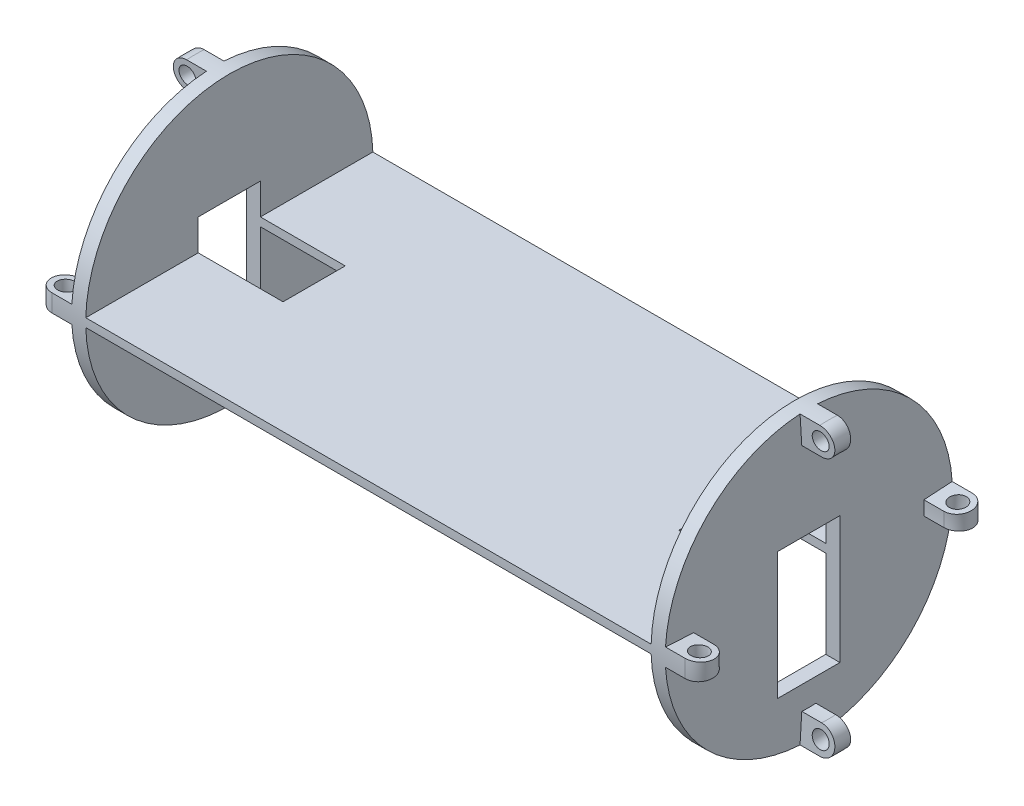
from build123d import *
from build123d.topology import SkipClean

# Parameters (mm, degrees)
SKETCH1_R               = 50.8
BOSS_EXTRUDE1_DEPTH     = 5
SKETCH2_W               = 22
SKETCH2_H               = 45
CUT_EXTRUDE1_DEPTH      = 5
SKETCH3_R               = 3
REVOLVE1_ANGLE          = 7
CIRPATTERN1_COUNT       = 4
SKETCH4_W               = 22
SKETCH4_H               = 3
BOSS_EXTRUDE2_DEPTH     = 200
SKETCH5_W               = 30
SKETCH5_H               = 22
CUT_EXTRUDE2_DEPTH      = 3
MIRROR1_COPY_1_SKETCH_R = 3
MIRROR1_COPY_1_ANGLE    = 7
MIRROR1_COPY_2_SKETCH_R = 3
MIRROR1_COPY_2_ANGLE    = 7
MIRROR1_COPY_3_SKETCH_R = 3
MIRROR1_COPY_3_ANGLE    = 7


with BuildPart() as part:
    # Sketch1 → Boss-Extrude1 (new body)
    with BuildSketch(Plane(origin=(0, 0, 0), x_dir=(0, 0, -1), z_dir=(1, 0, 0))):
        Circle(SKETCH1_R)
    boss_extrude1 = extrude(amount=-BOSS_EXTRUDE1_DEPTH)

    # Sketch2 → Cut-Extrude1 (cut)
    with BuildSketch(Plane(origin=(0, 0, 0), x_dir=(0, 0, -1), z_dir=(1, 0, 0))):
        with Locations((0, -10)):
            Rectangle(SKETCH2_W, SKETCH2_H)
    cut_extrude1 = extrude(amount=-CUT_EXTRUDE1_DEPTH, mode=Mode.SUBTRACT)

    # Sketch3 → Revolve1 (revolve, symmetric)
    with SkipClean():  # the faces are left unmerged after this step: merging them gives an invalid solid
        with BuildSketch(Plane.XY) as revolve1_sk:
            with BuildLine():
                Line((0, 50.8), (0, 40.8))
                Line((0, 40.8), (7, 40.8))
                ThreePointArc((7, 40.8), (12, 45.8), (7, 50.8))
                Line((7, 50.8), (0, 50.8))
            make_face()
            with Locations((7, 45.8)):
                Circle(SKETCH3_R, mode=Mode.SUBTRACT)
        revolve1 = revolve(axis=Axis((0, 0, 0), (1, 0, 0)), revolution_arc=REVOLVE1_ANGLE / 2)
        revolve1 = revolve1 + revolve(revolve1_sk.sketch, axis=Axis((0, 0, 0), (-1, 0, 0)), revolution_arc=REVOLVE1_ANGLE / 2)

    # CirPattern1: Revolve1 ×4 about axis
    cirpattern1_axis = Axis((-5, 0, 0), (1, 0, 0))
    for i in range(1, CIRPATTERN1_COUNT):
        add(revolve1.rotate(cirpattern1_axis, i * 360 / CIRPATTERN1_COUNT))

    # Sketch4 → Boss-Extrude2 (add)
    with BuildSketch(Plane.ZY.offset(5)):
        with BuildLine():
            ThreePointArc((50.8, 0), (50.794462074, 0.75008177), (50.777849502, 1.5))
            Line((50.777849502, 1.5), (11, 1.5))
            Line((11, 1.5), (11, -1.5))
            Line((11, -1.5), (50.777849502, -1.5))
            ThreePointArc((50.777849502, -1.5), (50.794462074, -0.75008177), (50.8, 0))
        make_face()
        Rectangle(SKETCH4_W, SKETCH4_H)
        with BuildLine():
            Line((-11, 1.5), (-50.777849502, 1.5))
            ThreePointArc((-50.777849502, 1.5), (-50.8, 0), (-50.777849502, -1.5))
            Line((-50.777849502, -1.5), (-11, -1.5))
            Line((-11, -1.5), (-11, 1.5))
        make_face()
    extrude(amount=BOSS_EXTRUDE2_DEPTH)

    # Sketch5 → Cut-Extrude2 (cut)
    with BuildSketch(Plane.XZ.offset(1.5)):
        with Locations((-20, 0)):
            Rectangle(SKETCH5_W, SKETCH5_H)
    cut_extrude2 = extrude(amount=-CUT_EXTRUDE2_DEPTH, mode=Mode.SUBTRACT)

    # Mirror1: Boss-Extrude1, Cut-Extrude1, Revolve1, Cut-Extrude2 across plane
    add(boss_extrude1.mirror(Plane.ZY.offset(105)))
    add(cut_extrude1.mirror(Plane.ZY.offset(105)), mode=Mode.SUBTRACT)
    add(revolve1.mirror(Plane.ZY.offset(105)))
    add(cut_extrude2.mirror(Plane.ZY.offset(105)), mode=Mode.SUBTRACT)

    # Mirror1 copy 1 sketch → Mirror1 copy 1 (revolve, symmetric)
    with SkipClean():  # the faces are left unmerged after this step: merging them gives an invalid solid
        with BuildSketch(Plane(origin=(-210, 0, 0), x_dir=(-1, 0, 0), z_dir=(0, -1, 0))) as mirror1_copy_1_sk:
            with BuildLine():
                Line((0, -50.8), (0, -40.8))
                Line((0, -40.8), (7, -40.8))
                ThreePointArc((7, -40.8), (12, -45.8), (7, -50.8))
                Line((7, -50.8), (0, -50.8))
            make_face()
            with Locations((7, -45.8)):
                Circle(MIRROR1_COPY_1_SKETCH_R, mode=Mode.SUBTRACT)
        revolve(axis=Axis((-210, 0, 0), (1, 0, 0)), revolution_arc=MIRROR1_COPY_1_ANGLE / 2)
        revolve(mirror1_copy_1_sk.sketch, axis=Axis((-210, 0, 0), (-1, 0, 0)), revolution_arc=MIRROR1_COPY_1_ANGLE / 2)

    # Mirror1 copy 2 sketch → Mirror1 copy 2 (revolve, symmetric)
    with SkipClean():  # the faces are left unmerged after this step: merging them gives an invalid solid
        with BuildSketch(Plane(origin=(-210, 0, 0), x_dir=(-1, 0, 0), z_dir=(0, 0, -1))) as mirror1_copy_2_sk:
            with BuildLine():
                Line((0, -50.8), (0, -40.8))
                Line((0, -40.8), (7, -40.8))
                ThreePointArc((7, -40.8), (12, -45.8), (7, -50.8))
                Line((7, -50.8), (0, -50.8))
            make_face()
            with Locations((7, -45.8)):
                Circle(MIRROR1_COPY_2_SKETCH_R, mode=Mode.SUBTRACT)
        revolve(axis=Axis((-210, 0, 0), (1, 0, 0)), revolution_arc=MIRROR1_COPY_2_ANGLE / 2)
        revolve(mirror1_copy_2_sk.sketch, axis=Axis((-210, 0, 0), (-1, 0, 0)), revolution_arc=MIRROR1_COPY_2_ANGLE / 2)

    # Mirror1 copy 3 sketch → Mirror1 copy 3 (revolve, symmetric)
    with SkipClean():  # the faces are left unmerged after this step: merging them gives an invalid solid
        with BuildSketch(Plane(origin=(-210, 0, 0), x_dir=(-1, 0, 0), z_dir=(0, 1, 0))) as mirror1_copy_3_sk:
            with BuildLine():
                Line((0, -50.8), (0, -40.8))
                Line((0, -40.8), (7, -40.8))
                ThreePointArc((7, -40.8), (12, -45.8), (7, -50.8))
                Line((7, -50.8), (0, -50.8))
            make_face()
            with Locations((7, -45.8)):
                Circle(MIRROR1_COPY_3_SKETCH_R, mode=Mode.SUBTRACT)
        revolve(axis=Axis((-210, 0, 0), (1, 0, 0)), revolution_arc=MIRROR1_COPY_3_ANGLE / 2)
        revolve(mirror1_copy_3_sk.sketch, axis=Axis((-210, 0, 0), (-1, 0, 0)), revolution_arc=MIRROR1_COPY_3_ANGLE / 2)


solid = part.part
